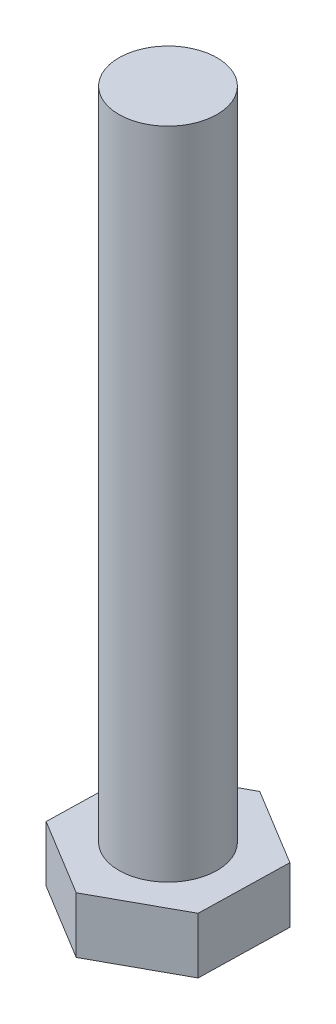
from build123d import *

# Parameters (mm, degrees)
EXTRUDE_1_DEPTH = 8
SKETCH_2_R      = 6
EXTRUDE_2_DEPTH = 80
CHAMFER_1_SIZE  = 2
CHAMFER_1_SIZE2 = 1.154700538


with BuildPart() as part:
    # Эскиз1 → Бобышка-Вытянуть1 (new body)
    with BuildSketch(Plane(origin=(0, 0, 0), x_dir=(1, 0, 0), z_dir=(0, 1, 0))):
        Polygon((9.374335606, -5.696943503), (9.620865601, 5.269941027), (0.246529995, 10.96688453), (-9.374335606, 5.696943503), (-9.620865601, -5.269941027), (-0.246529995, -10.96688453), align=None)
    extrude(amount=EXTRUDE_1_DEPTH)

    # Эскиз2 → Бобышка-Вытянуть2 (add)
    with BuildSketch(Plane(origin=(0, 8, 0), x_dir=(1, 0, 0), z_dir=(0, 1, 0))):
        Circle(SKETCH_2_R)
    extrude(amount=EXTRUDE_2_DEPTH)

    # Фаска1
    chamfer_1_edges = [part.edges().sort_by_distance(p)[0] for p in [
        (-4.933697798, 0, 8.118412778),
        (-9.497600603, 0, -0.213501238),
        (-4.563902806, 0, -8.331914017),
        (4.933697798, 0, -8.118412778),
        (9.497600603, 0, 0.213501238),
        (4.563902806, 0, 8.331914017),
    ]]
    chamfer_1_side = [part.faces().sort_by_distance(p)[0] for p in [
        (0, 0, 0),
    ]]
    chamfer(chamfer_1_edges, length=CHAMFER_1_SIZE, length2=CHAMFER_1_SIZE2, reference=chamfer_1_side[0])


solid = part.part
